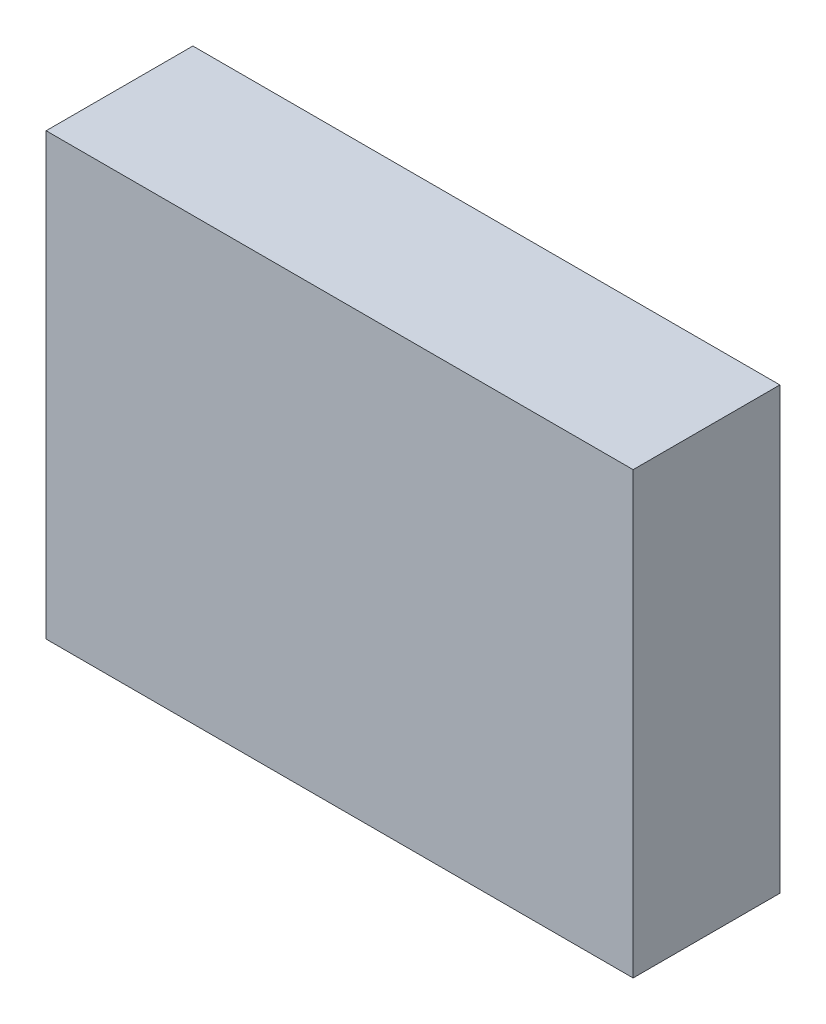
from build123d import *

# Parameters (mm, degrees)
SKETCH1_W           = 40
SKETCH1_H           = 30
BOSS_EXTRUDE1_DEPTH = 5


with BuildPart() as part:
    # Sketch1 → Boss-Extrude1 (new body, symmetric)
    with BuildSketch(Plane.XY):
        with Locations((0, 15)):
            Rectangle(SKETCH1_W, SKETCH1_H)
    extrude(amount=BOSS_EXTRUDE1_DEPTH, both=True)


solid = part.part
